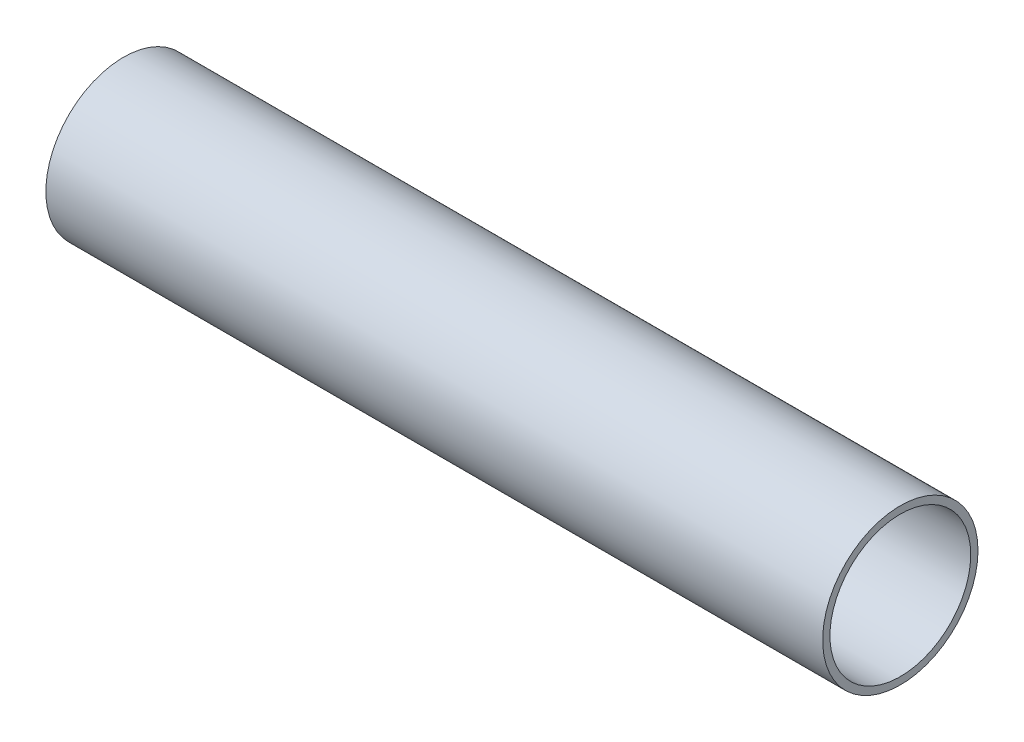
from build123d import *

# Parameters (mm, degrees)
SKETCH1_W = 80
SKETCH1_H = 0.75


with BuildPart() as part:
    # Sketch1 → Revolve1 (revolve)
    with BuildSketch(Plane.XY):
        with Locations((40, 7.625)):
            Rectangle(SKETCH1_W, SKETCH1_H)
    revolve(axis=Axis((0, 0, 0), (1, 0, 0)))


solid = part.part
